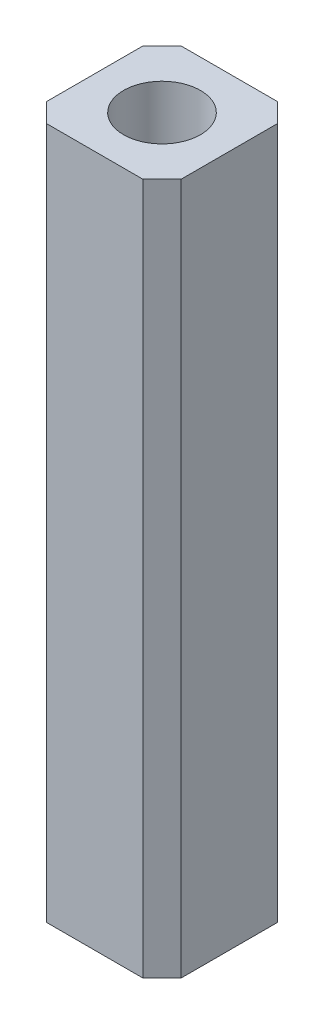
from build123d import *

# Parameters (mm, degrees)
SKETCH1_W           = 3.5
SKETCH1_H           = 3.5
SKETCH1_R           = 1
BOSS_EXTRUDE1_DEPTH = 18
CHAMFER1_SIZE       = 0.5


with BuildPart() as part:
    # Sketch1 → Boss-Extrude1 (new body)
    with BuildSketch(Plane(origin=(0, 0, 0), x_dir=(1, 0, 0), z_dir=(0, 1, 0))):
        Rectangle(SKETCH1_W, SKETCH1_H)
        Circle(SKETCH1_R, mode=Mode.SUBTRACT)
    extrude(amount=BOSS_EXTRUDE1_DEPTH)

    # Chamfer1
    chamfer1_edges = [part.edges().sort_by_distance(p)[0] for p in [
        (1.75, 9, 1.75),
        (-1.75, 9, 1.75),
        (-1.75, 9, -1.75),
        (1.75, 9, -1.75),
    ]]
    chamfer(chamfer1_edges, length=CHAMFER1_SIZE)


solid = part.part
